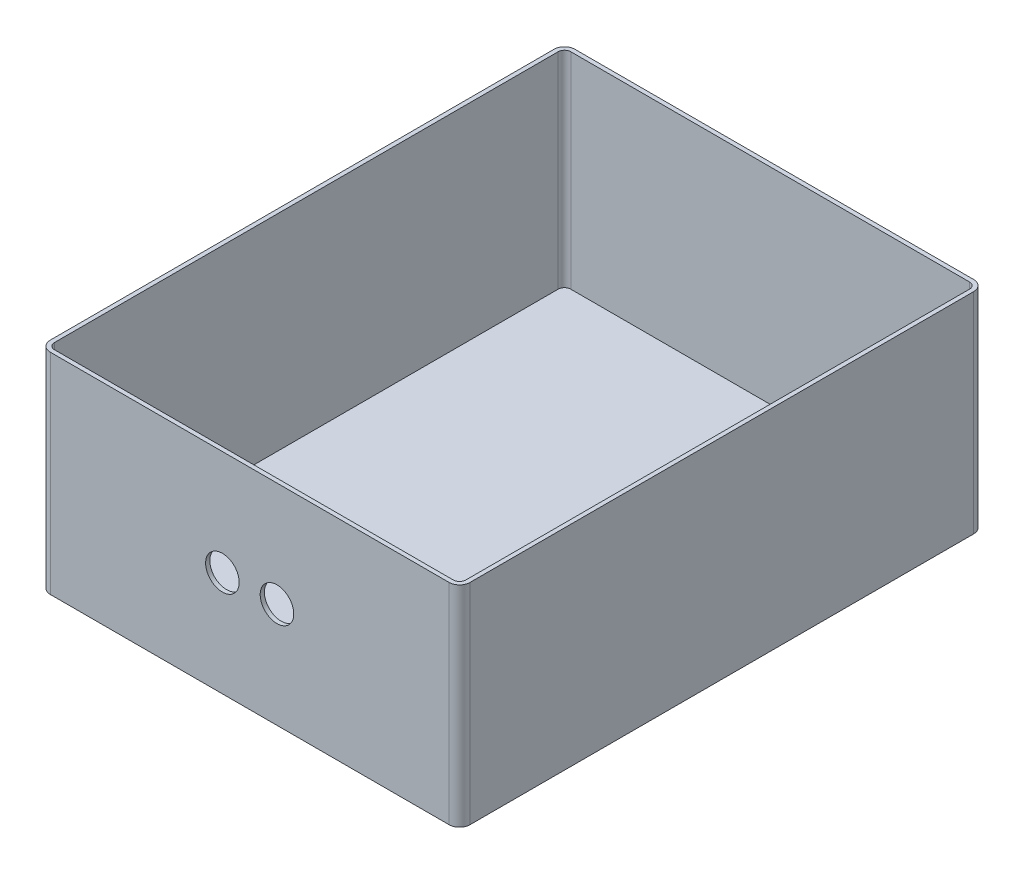
from build123d import *

# Parameters (mm, degrees)
BOSS_EXTRUDE2_DEPTH = 100
SHELL2_T            = -2
SKETCH5_R           = 8
CUT_EXTRUDE1_DEPTH  = 100


with BuildPart() as part:
    # Sketch3 → Boss-Extrude2 (new body)
    with BuildSketch(Plane(origin=(0, 0, 0), x_dir=(1, 0, 0), z_dir=(0, 1, 0))):
        with BuildLine():
            Line((184.402855292, 224.204318802), (89.402855292, 224.204318802))
            Line((89.402855292, 224.204318802), (-5.597144708, 224.204318802))
            ThreePointArc((-5.597144708, 224.204318802), (-9.132678614, 222.739852708), (-10.597144708, 219.204318802))
            Line((-10.597144708, 219.204318802), (-10.597144708, -20.795681198))
            ThreePointArc((-10.597144708, -20.795681198), (-9.132678614, -24.331215104), (-5.597144708, -25.795681198))
            Line((-5.597144708, -25.795681198), (89.402855292, -25.795681198))
            Line((89.402855292, -25.795681198), (184.402855292, -25.795681198))
            ThreePointArc((184.402855292, -25.795681198), (187.938389198, -24.331215104), (189.402855292, -20.795681198))
            Line((189.402855292, -20.795681198), (189.402855292, 219.204318802))
            ThreePointArc((189.402855292, 219.204318802), (187.938389198, 222.739852708), (184.402855292, 224.204318802))
        make_face()
    extrude(amount=BOSS_EXTRUDE2_DEPTH)

    # Shell2
    shell2_openings = [part.faces().sort_by_distance(p)[0] for p in [
        (89.402855292, 100, -99.204318802),
    ]]
    offset(amount=SHELL2_T, openings=shell2_openings, kind=Kind.INTERSECTION)

    # Sketch5 → Cut-Extrude1 (cut)
    with BuildSketch(Plane.XY.offset(25.795681198)):
        with Locations((76.402855292, 50)):
            Circle(SKETCH5_R)
        with Locations((102.402855292, 50)):
            Circle(SKETCH5_R)
    extrude(amount=-CUT_EXTRUDE1_DEPTH, mode=Mode.SUBTRACT)


solid = part.part
